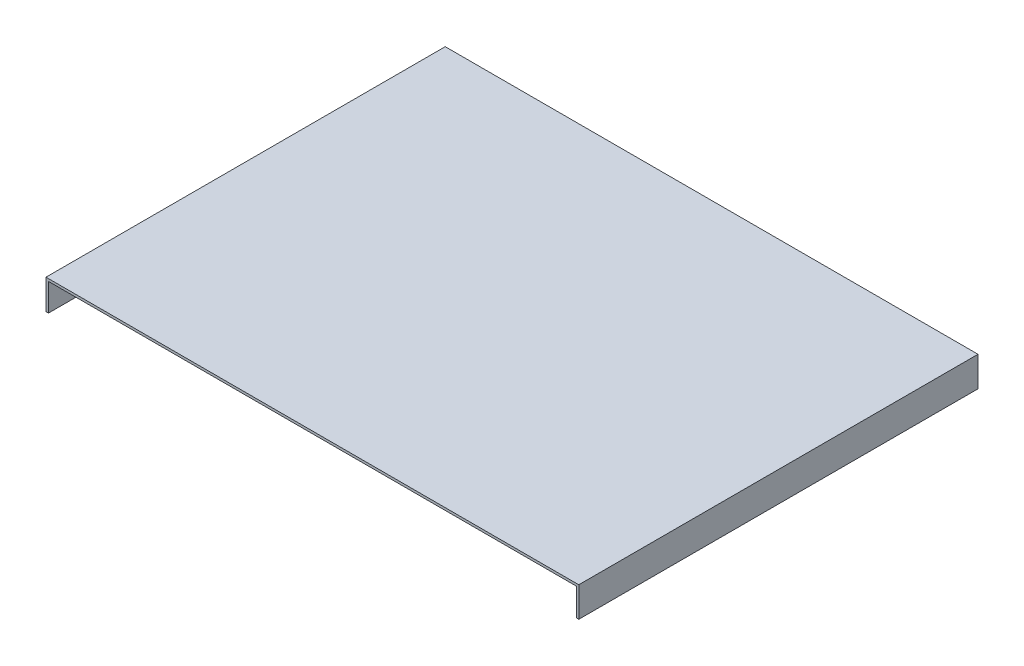
from build123d import *

# Parameters (mm, degrees)
SZKIC1_W                    = 387
SZKIC1_H                    = 1.75
DODANIE_WYCI_GNI_CIE1_DEPTH = 290
DODANIE_WYCI_GNI_CIE2_DEPTH = 20


with BuildPart() as part:
    # Szkic1 → Dodanie-wyciągnięcie1 (new body)
    with BuildSketch(Plane.XY):
        with Locations((0, -0.875)):
            Rectangle(SZKIC1_W, SZKIC1_H)
    extrude(amount=DODANIE_WYCI_GNI_CIE1_DEPTH)

    # Szkic2 → Dodanie-wyciągnięcie2 (add)
    with BuildSketch(Plane.XZ.offset(1.75)):
        Polygon((-193.5, 290), (-193.5, 0), (193.5, 0), (193.5, 290), (191.75, 290), (191.75, 1.75), (-191.75, 1.75), (-191.75, 290), align=None)
    extrude(amount=DODANIE_WYCI_GNI_CIE2_DEPTH)


solid = part.part
